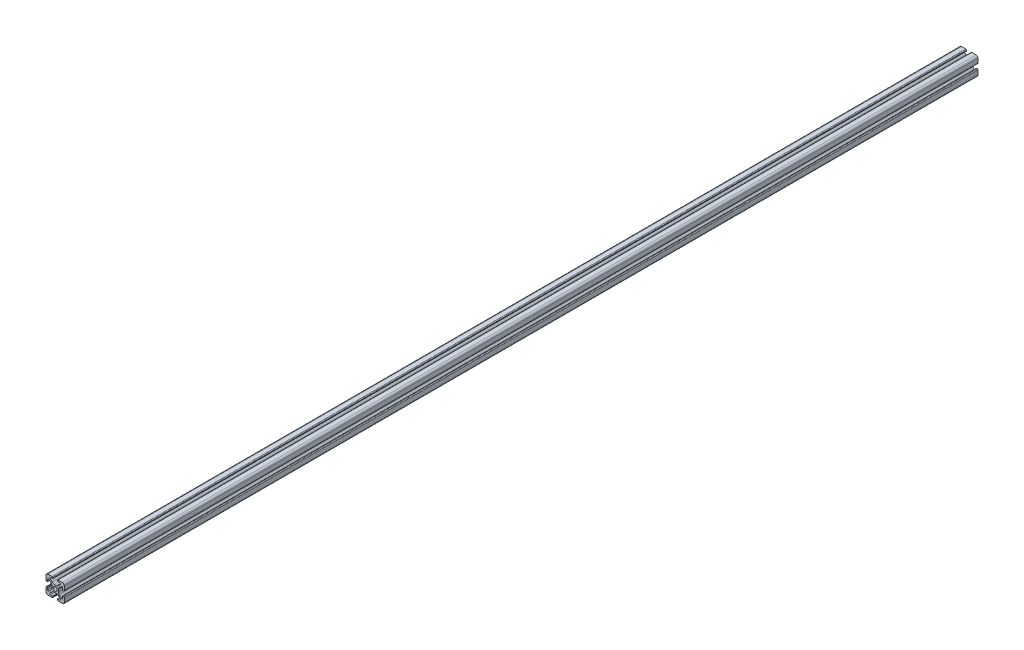
from build123d import *

# Parameters (mm, degrees)
SKETCH1_R           = 2.1463
BOSS_EXTRUDE1_DEPTH = 500.0625


with BuildPart() as part:
    # Sketch1 → Boss-Extrude1 (new body, symmetric)
    with BuildSketch(Plane.XY):
        with BuildLine():
            Line((-9.9949, 7.9883), (-9.9949, 3.2893))
            ThreePointArc((-9.9949, 3.2893), (-9.76427588, 2.73252412), (-9.2075, 2.5019))
            Line((-9.2075, 2.5019), (-8.4963, 2.5019))
            ThreePointArc((-8.4963, 2.5019), (-8.280773853, 2.591173853), (-8.1915, 2.8067))
            Line((-8.1915, 2.8067), (-8.1915, 4.9149))
            ThreePointArc((-8.1915, 4.9149), (-7.674065253, 5.689295824), (-6.760603096, 5.507596904))
            Line((-6.760603096, 5.507596904), (-4.505765747, 3.252759555))
            ThreePointArc((-4.505765747, 3.252759555), (-3.856054457, 2.280397894), (-3.627906192, 1.133419111))
            Line((-3.627906192, 1.133419111), (-3.627906192, -1.133419111))
            ThreePointArc((-3.627906192, -1.133419111), (-3.856054457, -2.280397894), (-4.505765747, -3.252759555))
            Line((-4.505765747, -3.252759555), (-6.760603096, -5.507596904))
            ThreePointArc((-6.760603096, -5.507596904), (-7.674065253, -5.689295824), (-8.1915, -4.9149))
            Line((-8.1915, -4.9149), (-8.1915, -2.8067))
            ThreePointArc((-8.1915, -2.8067), (-8.280773853, -2.591173853), (-8.4963, -2.5019))
            Line((-8.4963, -2.5019), (-9.2075, -2.5019))
            ThreePointArc((-9.2075, -2.5019), (-9.76427588, -2.73252412), (-9.9949, -3.2893))
            Line((-9.9949, -3.2893), (-9.9949, -7.9883))
            ThreePointArc((-9.9949, -7.9883), (-9.407180467, -9.407180467), (-7.9883, -9.9949))
            Line((-7.9883, -9.9949), (-3.2893, -9.9949))
            ThreePointArc((-3.2893, -9.9949), (-2.73252412, -9.76427588), (-2.5019, -9.2075))
            Line((-2.5019, -9.2075), (-2.5019, -8.4963))
            ThreePointArc((-2.5019, -8.4963), (-2.591173853, -8.280773853), (-2.8067, -8.1915))
            Line((-2.8067, -8.1915), (-4.9149, -8.1915))
            ThreePointArc((-4.9149, -8.1915), (-5.689295824, -7.674065253), (-5.507596904, -6.760603096))
            Line((-5.507596904, -6.760603096), (-3.252759555, -4.505765747))
            ThreePointArc((-3.252759555, -4.505765747), (-2.280397894, -3.856054457), (-1.133419111, -3.627906192))
            Line((-1.133419111, -3.627906192), (1.133419111, -3.627906192))
            ThreePointArc((1.133419111, -3.627906192), (2.280397894, -3.856054457), (3.252759555, -4.505765747))
            Line((3.252759555, -4.505765747), (5.507596904, -6.760603096))
            ThreePointArc((5.507596904, -6.760603096), (5.689295824, -7.674065253), (4.9149, -8.1915))
            Line((4.9149, -8.1915), (2.8067, -8.1915))
            ThreePointArc((2.8067, -8.1915), (2.591173853, -8.280773853), (2.5019, -8.4963))
            Line((2.5019, -8.4963), (2.5019, -9.2075))
            ThreePointArc((2.5019, -9.2075), (2.73252412, -9.76427588), (3.2893, -9.9949))
            Line((3.2893, -9.9949), (7.9883, -9.9949))
            ThreePointArc((7.9883, -9.9949), (9.407180467, -9.407180467), (9.9949, -7.9883))
            Line((9.9949, -7.9883), (9.9949, -3.2893))
            ThreePointArc((9.9949, -3.2893), (9.76427588, -2.73252412), (9.2075, -2.5019))
            Line((9.2075, -2.5019), (8.4963, -2.5019))
            ThreePointArc((8.4963, -2.5019), (8.280773853, -2.591173853), (8.1915, -2.8067))
            Line((8.1915, -2.8067), (8.1915, -4.9149))
            ThreePointArc((8.1915, -4.9149), (7.674065253, -5.689295824), (6.760603096, -5.507596904))
            Line((6.760603096, -5.507596904), (4.505765747, -3.252759555))
            ThreePointArc((4.505765747, -3.252759555), (3.856054457, -2.280397894), (3.627906192, -1.133419111))
            Line((3.627906192, -1.133419111), (3.627906192, 1.133419111))
            ThreePointArc((3.627906192, 1.133419111), (3.856054457, 2.280397894), (4.505765747, 3.252759555))
            Line((4.505765747, 3.252759555), (6.760603096, 5.507596904))
            ThreePointArc((6.760603096, 5.507596904), (7.674065253, 5.689295824), (8.1915, 4.9149))
            Line((8.1915, 4.9149), (8.1915, 2.8067))
            ThreePointArc((8.1915, 2.8067), (8.280773853, 2.591173853), (8.4963, 2.5019))
            Line((8.4963, 2.5019), (9.2075, 2.5019))
            ThreePointArc((9.2075, 2.5019), (9.76427588, 2.73252412), (9.9949, 3.2893))
            Line((9.9949, 3.2893), (9.9949, 7.9883))
            ThreePointArc((9.9949, 7.9883), (9.407180467, 9.407180467), (7.9883, 9.9949))
            Line((7.9883, 9.9949), (3.2893, 9.9949))
            ThreePointArc((3.2893, 9.9949), (2.73252412, 9.76427588), (2.5019, 9.2075))
            Line((2.5019, 9.2075), (2.5019, 8.4963))
            ThreePointArc((2.5019, 8.4963), (2.591173853, 8.280773853), (2.8067, 8.1915))
            Line((2.8067, 8.1915), (4.9149, 8.1915))
            ThreePointArc((4.9149, 8.1915), (5.689295824, 7.674065253), (5.507596904, 6.760603096))
            Line((5.507596904, 6.760603096), (3.252759555, 4.505765747))
            ThreePointArc((3.252759555, 4.505765747), (2.280397894, 3.856054457), (1.133419111, 3.627906192))
            Line((1.133419111, 3.627906192), (-1.133419111, 3.627906192))
            ThreePointArc((-1.133419111, 3.627906192), (-2.280397894, 3.856054457), (-3.252759555, 4.505765747))
            Line((-3.252759555, 4.505765747), (-5.507596904, 6.760603096))
            ThreePointArc((-5.507596904, 6.760603096), (-5.689295824, 7.674065253), (-4.9149, 8.1915))
            Line((-4.9149, 8.1915), (-2.8067, 8.1915))
            ThreePointArc((-2.8067, 8.1915), (-2.591173853, 8.280773853), (-2.5019, 8.4963))
            Line((-2.5019, 8.4963), (-2.5019, 9.2075))
            ThreePointArc((-2.5019, 9.2075), (-2.73252412, 9.76427588), (-3.2893, 9.9949))
            Line((-3.2893, 9.9949), (-7.9883, 9.9949))
            ThreePointArc((-7.9883, 9.9949), (-9.407180467, 9.407180467), (-9.9949, 7.9883))
        make_face()
        Circle(SKETCH1_R, mode=Mode.SUBTRACT)
    extrude(amount=BOSS_EXTRUDE1_DEPTH, both=True)


solid = part.part
